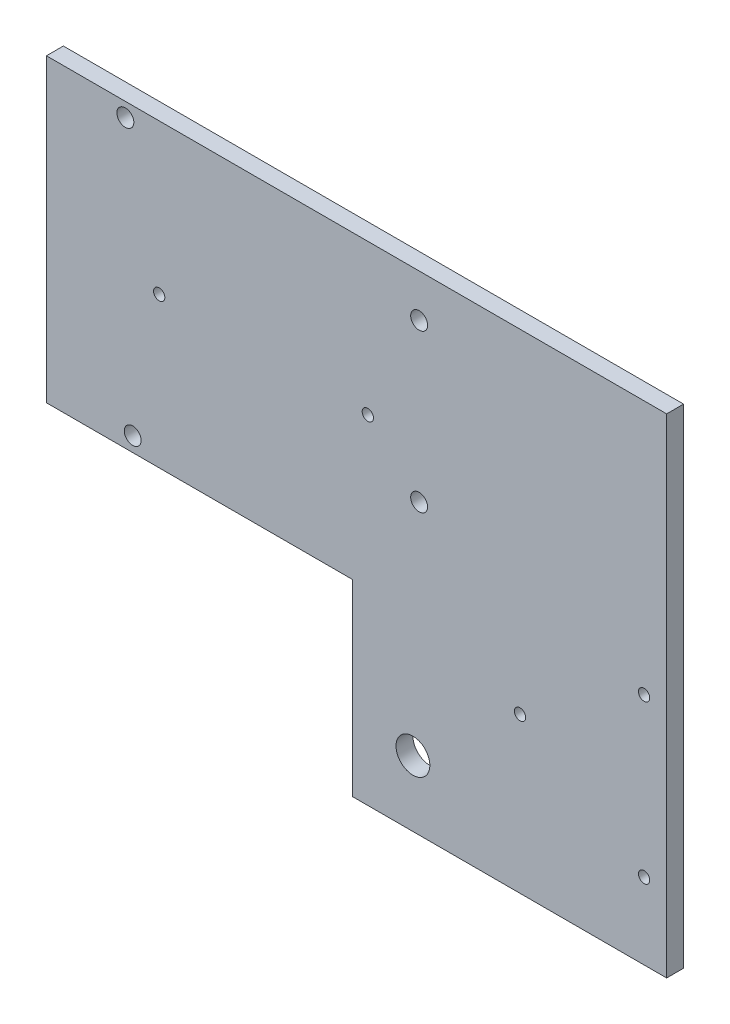
from build123d import *

# Parameters (mm, degrees)
MODEL_R             = 1.5
MODEL_R_2           = 1
MODEL_R_3           = 3
BOSS_EXTRUDE1_DEPTH = 3


with BuildPart() as part:
    # Model → Boss-Extrude1 (new body)
    with BuildSketch(Plane.XY):
        Polygon((26.589929576, 98.91813413), (26.589929576, 45.61813413), (80.889929576, 45.61813413), (80.889929576, 12.26813413), (136.589929576, 12.26813413), (136.589929576, 45.61813413), (136.589929576, 98.91813413), align=None)
        with Locations((40.589929576, 96.41813413)):
            Circle(MODEL_R, mode=Mode.SUBTRACT)
        with Locations((92.689929576, 63.41813413)):
            Circle(MODEL_R, mode=Mode.SUBTRACT)
        with Locations((41.889929576, 48.21813413)):
            Circle(MODEL_R, mode=Mode.SUBTRACT)
        with Locations((92.689929576, 91.31813413)):
            Circle(MODEL_R, mode=Mode.SUBTRACT)
        with Locations((110.589929576, 39.76813413)):
            Circle(MODEL_R_2, mode=Mode.SUBTRACT)
        with Locations((46.589929576, 72.26813413)):
            Circle(MODEL_R_2, mode=Mode.SUBTRACT)
        with Locations((83.589929576, 72.26813413)):
            Circle(MODEL_R_2, mode=Mode.SUBTRACT)
        with Locations((132.589929576, 25.76813413)):
            Circle(MODEL_R_2, mode=Mode.SUBTRACT)
        with Locations((91.589929576, 23.91813413)):
            Circle(MODEL_R_3, mode=Mode.SUBTRACT)
        with Locations((132.589929576, 53.76813413)):
            Circle(MODEL_R_2, mode=Mode.SUBTRACT)
    extrude(amount=BOSS_EXTRUDE1_DEPTH)


solid = part.part
